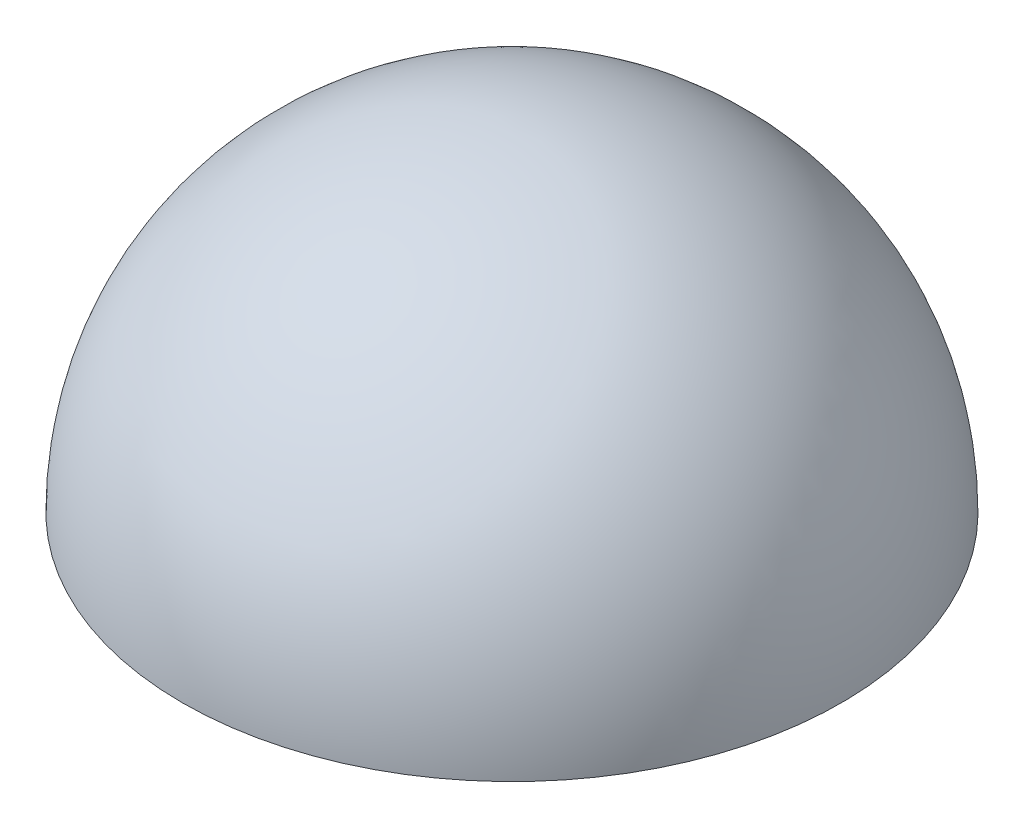
from build123d import *

# Parameters (mm, degrees)
REVOLVE3_ANGLE     = 180
CUT_REVOLVE1_ANGLE = 180


with BuildPart() as part:
    # Sketch1 → Revolve3 (revolve)
    with BuildSketch(Plane(origin=(0, 0, 0), x_dir=(1, 0, 0), z_dir=(0, 1, 0))):
        with BuildLine():
            Line((0, -19.05), (0, 19.05))
            ThreePointArc((0, 19.05), (-19.05, 0), (0, -19.05))
        make_face()
    revolve(axis=Axis((0, 0, 19.05), (0, 0, -1)), revolution_arc=REVOLVE3_ANGLE)

    # Sketch2 → Cut-Revolve1 (revolve, cut)
    with BuildSketch(Plane.XZ):
        with BuildLine():
            Line((-12.7, 0), (12.7, 0))
            ThreePointArc((12.7, 0), (0, 12.7), (-12.7, 0))
        make_face()
    revolve(axis=Axis((-12.7, 0, 0), (-1, 0, 0)), revolution_arc=CUT_REVOLVE1_ANGLE, mode=Mode.SUBTRACT)


solid = part.part
